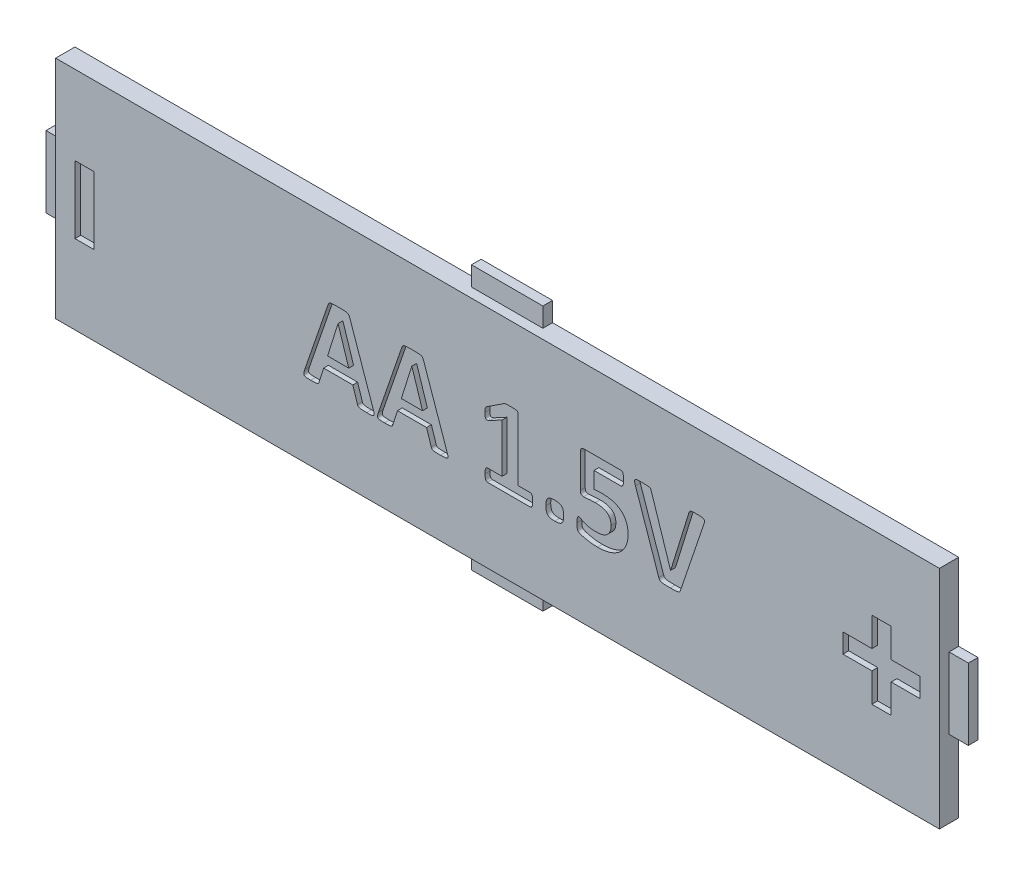
from build123d import *

# Parameters (mm, degrees)
BOSS_EXTRUDE1_DEPTH = 1
CUT_EXTRUDE1_DEPTH  = 0.25
SKETCH4_W           = 2.1
SKETCH4_H           = 2.1
CUT_EXTRUDE3_DEPTH  = 0.5
FILLET2_R           = 0.4
SKETCH6_W           = 1
SKETCH6_H           = 3.5
CUT_EXTRUDE4_DEPTH  = 0.3
SKETCH7_W           = 1
SKETCH7_H           = 3.7
SKETCH7_W_2         = 3.7
SKETCH7_H_2         = 1
CUT_EXTRUDE5_DEPTH  = 0.5


with BuildPart() as part:
    # Sketch1 → Boss-Extrude1 (new body)
    with BuildSketch(Plane.XY):
        Polygon((-22.9, -5.85), (-1.85, -5.85), (-1.85, -6.85), (1.85, -6.85), (1.85, -5.85), (22.9, -5.85), (22.9, -1.85), (23.9, -1.85), (23.9, 1.85), (22.9, 1.85), (22.9, 5.85), (1.85, 5.85), (1.85, 6.85), (-1.85, 6.85), (-1.85, 5.85), (-22.9, 5.85), (-22.9, 1.85), (-23.9, 1.85), (-23.9, -1.85), (-22.9, -1.85), align=None)
    extrude(amount=BOSS_EXTRUDE1_DEPTH)

    # Sketch2 → Cut-Extrude1 (cut)
    with BuildSketch(Plane.XY.offset(1)):
        with BuildLine():
            add(Edge.make_bspline(
                [(-6.441176471, -1.681066176), (-6.43514215, -1.698463246), (-6.423893064, -1.73089459), (-6.411134097, -1.777714399), (-6.400914328, -1.81840243), (-6.393947438, -1.853881891), (-6.391326647, -1.884608418), (-6.39520632, -1.911109035), (-6.403122486, -1.934523301), (-6.418807872, -1.953302348), (-6.439899264, -1.968606454), (-6.467908333, -1.979050301), (-6.501623162, -1.988432883), (-6.542462837, -1.993400755), (-6.590374631, -1.995378977), (-6.645792762, -1.998848309), (-6.709870331, -1.998953944), (-6.755210304, -1.999635957), (-6.779411765, -2)],
                knots=[0, 0, 0, 0, 5.5224e-05, 0.000102947, 0.000145525, 0.000181039, 0.000211426, 0.000237422, 0.000260981, 0.000284522, 0.000309525, 0.000338371, 0.000373598, 0.000414414, 0.00046137, 0.000517504, 0.00058093, 0.000653546, 0.000653546, 0.000653546, 0.000653546], degree=3))
            add(Edge.make_bspline(
                [(-6.779411765, -2), (-6.804227611, -2.000059076), (-6.851104114, -2.000170668), (-6.916990313, -1.999438733), (-6.974262144, -1.997235534), (-7.035664591, -1.995552473), (-7.097179219, -1.989698559), (-7.156329437, -1.980048369), (-7.198777842, -1.963881988), (-7.227688195, -1.940038839), (-7.24419154, -1.908504263), (-7.252150138, -1.886125934), (-7.256433824, -1.874080882)],
                knots=[0, 0, 0, 0, 7.4449e-05, 0.000140631, 0.000197646, 0.000246394, 0.000324864, 0.000382907, 0.000425752, 0.000459648, 0.000492595, 0.000531001, 0.000531001, 0.000531001, 0.000531001], degree=3))
            Line((-7.256433824, -1.874080882), (-7.500919118, -1.117647059))
            Line((-7.500919118, -1.117647059), (-9.010110294, -1.117647059))
            Line((-9.010110294, -1.117647059), (-9.241727941, -1.852941176))
            add(Edge.make_bspline(
                [(-9.241727941, -1.852941176), (-9.245919816, -1.86624811), (-9.253902368, -1.891588393), (-9.272028902, -1.926589366), (-9.301223981, -1.954190463), (-9.342387527, -1.974913155), (-9.399235471, -1.987349905), (-9.473663173, -1.996392786), (-9.570163526, -1.998447493), (-9.641859217, -1.999442899), (-9.681985294, -2)],
                knots=[0, 0, 0, 0, 4.1858e-05, 7.9709e-05, 0.00011676, 0.000160338, 0.000216291, 0.000290393, 0.000385133, 0.000505552, 0.000505552, 0.000505552, 0.000505552], degree=3))
            add(Edge.make_bspline(
                [(-9.681985294, -2), (-9.704351499, -1.999769411), (-9.746640373, -1.999333426), (-9.806400512, -1.997568311), (-9.858491194, -1.994780433), (-9.903390712, -1.991668492), (-9.941045498, -1.985572768), (-9.97271125, -1.976296067), (-9.998311499, -1.964078749), (-10.024660548, -1.942534901), (-10.042135205, -1.900772413), (-10.040106686, -1.839358846), (-10.02070276, -1.763253372), (-10.002794458, -1.706685478), (-9.992647059, -1.674632353)],
                knots=[0, 0, 0, 0, 6.7102e-05, 0.000126873, 0.000179335, 0.000223606, 0.000261835, 0.000293528, 0.000322301, 0.000346426, 0.000394123, 0.000451116, 0.000528278, 0.000629168, 0.000629168, 0.000629168, 0.000629168], degree=3))
            Line((-9.992647059, -1.674632353), (-8.783088235, 1.840992647))
            add(Edge.make_bspline(
                [(-8.783088235, 1.840992647), (-8.776768306, 1.856793782), (-8.765081152, 1.886014088), (-8.741799782, 1.925905888), (-8.706874844, 1.95706308), (-8.656070861, 1.97630304), (-8.589651982, 1.990860253), (-8.521210497, 1.995308723), (-8.45527723, 1.997267632), (-8.395539456, 1.99939096), (-8.328127436, 2.000182536), (-8.280637372, 2.000063154), (-8.255514706, 2)],
                knots=[0, 0, 0, 0, 5.105e-05, 9.4405e-05, 0.000137378, 0.000188428, 0.000255322, 0.000341116, 0.000393538, 0.000453309, 0.000520411, 0.000595778, 0.000595778, 0.000595778, 0.000595778], degree=3))
            add(Edge.make_bspline(
                [(-8.255514706, 2), (-8.226715577, 2.000060532), (-8.171872879, 2.000175804), (-8.094351935, 1.999407864), (-8.026033407, 1.997289207), (-7.951534629, 1.995274375), (-7.875169887, 1.991036748), (-7.80104759, 1.976372259), (-7.745233752, 1.95675726), (-7.706343614, 1.924201189), (-7.681056865, 1.881268088), (-7.669740277, 1.849195453), (-7.663602941, 1.831801471)],
                knots=[0, 0, 0, 0, 8.6397e-05, 0.000164527, 0.000232567, 0.000291419, 0.000388206, 0.00046139, 0.000517884, 0.000563545, 0.000610212, 0.000665512, 0.000665512, 0.000665512, 0.000665512], degree=3))
            Line((-7.663602941, 1.831801471), (-6.441176471, -1.681066176))
        make_face()
        Polygon((-8.264705882, 1.252757353), (-8.267463235, 1.252757353), (-8.806985294, -0.470588235), (-7.709558824, -0.470588235), align=None, mode=Mode.SUBTRACT)
        with BuildLine():
            add(Edge.make_bspline(
                [(-2.617647059, -1.681066176), (-2.611612738, -1.698463246), (-2.600363653, -1.73089459), (-2.587604685, -1.777714399), (-2.577384916, -1.81840243), (-2.570418026, -1.853881891), (-2.567797235, -1.884608418), (-2.571676909, -1.911109035), (-2.579593074, -1.934523301), (-2.59527846, -1.953302348), (-2.616369852, -1.968606454), (-2.644378921, -1.979050301), (-2.67809375, -1.988432883), (-2.718933426, -1.993400755), (-2.76684522, -1.995378977), (-2.82226335, -1.998848309), (-2.886340919, -1.998953944), (-2.931680892, -1.999635957), (-2.955882353, -2)],
                knots=[0, 0, 0, 0, 5.5224e-05, 0.000102947, 0.000145525, 0.000181039, 0.000211426, 0.000237422, 0.000260981, 0.000284522, 0.000309525, 0.000338371, 0.000373598, 0.000414414, 0.00046137, 0.000517504, 0.00058093, 0.000653546, 0.000653546, 0.000653546, 0.000653546], degree=3))
            add(Edge.make_bspline(
                [(-2.955882353, -2), (-2.980698199, -2.000059076), (-3.027574703, -2.000170668), (-3.093460901, -1.999438733), (-3.150732732, -1.997235534), (-3.212135179, -1.995552473), (-3.273649807, -1.989698559), (-3.332800026, -1.980048369), (-3.37524843, -1.963881988), (-3.404158783, -1.940038839), (-3.420662129, -1.908504263), (-3.428620726, -1.886125934), (-3.432904412, -1.874080882)],
                knots=[0, 0, 0, 0, 7.4449e-05, 0.000140631, 0.000197646, 0.000246394, 0.000324864, 0.000382907, 0.000425752, 0.000459648, 0.000492595, 0.000531001, 0.000531001, 0.000531001, 0.000531001], degree=3))
            Line((-3.432904412, -1.874080882), (-3.677389706, -1.117647059))
            Line((-3.677389706, -1.117647059), (-5.186580882, -1.117647059))
            Line((-5.186580882, -1.117647059), (-5.418198529, -1.852941176))
            add(Edge.make_bspline(
                [(-5.418198529, -1.852941176), (-5.422390404, -1.86624811), (-5.430372956, -1.891588393), (-5.44849949, -1.926589366), (-5.477694569, -1.954190463), (-5.518858115, -1.974913155), (-5.57570606, -1.987349905), (-5.650133761, -1.996392786), (-5.746634114, -1.998447493), (-5.818329805, -1.999442899), (-5.858455882, -2)],
                knots=[0, 0, 0, 0, 4.1858e-05, 7.9709e-05, 0.00011676, 0.000160338, 0.000216291, 0.000290393, 0.000385133, 0.000505552, 0.000505552, 0.000505552, 0.000505552], degree=3))
            add(Edge.make_bspline(
                [(-5.858455882, -2), (-5.880822087, -1.999769411), (-5.923110961, -1.999333426), (-5.9828711, -1.997568311), (-6.034961783, -1.994780433), (-6.0798613, -1.991668492), (-6.117516086, -1.985572768), (-6.149181838, -1.976296067), (-6.174782087, -1.964078749), (-6.201131136, -1.942534901), (-6.218605793, -1.900772413), (-6.216577274, -1.839358846), (-6.197173348, -1.763253372), (-6.179265047, -1.706685478), (-6.169117647, -1.674632353)],
                knots=[0, 0, 0, 0, 6.7102e-05, 0.000126873, 0.000179335, 0.000223606, 0.000261835, 0.000293528, 0.000322301, 0.000346426, 0.000394123, 0.000451116, 0.000528278, 0.000629168, 0.000629168, 0.000629168, 0.000629168], degree=3))
            Line((-6.169117647, -1.674632353), (-4.959558824, 1.840992647))
            add(Edge.make_bspline(
                [(-4.959558824, 1.840992647), (-4.953238894, 1.856793782), (-4.941551741, 1.886014088), (-4.91827037, 1.925905888), (-4.883345433, 1.95706308), (-4.83254145, 1.97630304), (-4.76612257, 1.990860253), (-4.697681085, 1.995308723), (-4.631747818, 1.997267632), (-4.572010044, 1.99939096), (-4.504598024, 2.000182536), (-4.45710796, 2.000063154), (-4.431985294, 2)],
                knots=[0, 0, 0, 0, 5.105e-05, 9.4405e-05, 0.000137378, 0.000188428, 0.000255322, 0.000341116, 0.000393538, 0.000453309, 0.000520411, 0.000595778, 0.000595778, 0.000595778, 0.000595778], degree=3))
            add(Edge.make_bspline(
                [(-4.431985294, 2), (-4.403186165, 2.000060532), (-4.348343467, 2.000175804), (-4.270822524, 1.999407864), (-4.202503995, 1.997289207), (-4.128005217, 1.995274375), (-4.051640475, 1.991036748), (-3.977518178, 1.976372259), (-3.92170434, 1.95675726), (-3.882814203, 1.924201189), (-3.857527453, 1.881268088), (-3.846210865, 1.849195453), (-3.840073529, 1.831801471)],
                knots=[0, 0, 0, 0, 8.6397e-05, 0.000164527, 0.000232567, 0.000291419, 0.000388206, 0.00046139, 0.000517884, 0.000563545, 0.000610212, 0.000665512, 0.000665512, 0.000665512, 0.000665512], degree=3))
            Line((-3.840073529, 1.831801471), (-2.617647059, -1.681066176))
        make_face()
        Polygon((-4.441176471, 1.252757353), (-4.443933824, 1.252757353), (-4.983455882, -0.470588235), (-3.886029412, -0.470588235), align=None, mode=Mode.SUBTRACT)
        with BuildLine():
            add(Edge.make_bspline(
                [(1.823529412, -1.681066176), (1.823463336, -1.708670782), (1.823341898, -1.759404012), (1.815553837, -1.828767687), (1.805678764, -1.885535073), (1.79009576, -1.929490513), (1.771757062, -1.962408316), (1.750141338, -1.984620328), (1.725346823, -1.998330266), (1.707581573, -1.999436385), (1.698529412, -2)],
                knots=[0, 0, 0, 0, 8.2741e-05, 0.000152066, 0.000209207, 0.000255144, 0.0002914, 0.000321296, 0.000347195, 0.000374102, 0.000374102, 0.000374102, 0.000374102], degree=3))
            Line((1.698529412, -2), (-0.525735294, -2))
            add(Edge.make_bspline(
                [(-0.525735294, -2), (-0.533828139, -1.999297033), (-0.550589773, -1.99784107), (-0.574550612, -1.984881933), (-0.595190944, -1.962021237), (-0.613710959, -1.929566078), (-0.629121518, -1.885502034), (-0.639390772, -1.828835037), (-0.645359368, -1.759317359), (-0.646459683, -1.7086535), (-0.647058824, -1.681066176)],
                knots=[0, 0, 0, 0, 2.4178e-05, 5.0077e-05, 7.933e-05, 0.000115586, 0.000161524, 0.000218664, 0.000287898, 0.000370664, 0.000370664, 0.000370664, 0.000370664], degree=3))
            add(Edge.make_bspline(
                [(-0.647058824, -1.681066176), (-0.646699586, -1.652881612), (-0.646042735, -1.601347219), (-0.641661078, -1.530748077), (-0.630471054, -1.473814673), (-0.616373386, -1.428606742), (-0.597911975, -1.3945121), (-0.576675694, -1.36995921), (-0.55104218, -1.355766058), (-0.532935014, -1.353881719), (-0.523897059, -1.352941176)],
                knots=[0, 0, 0, 0, 8.4579e-05, 0.000154649, 0.00021179, 0.000258294, 0.000296145, 0.000327368, 0.00035451, 0.000381557, 0.000381557, 0.000381557, 0.000381557], degree=3))
            Line((-0.523897059, -1.352941176), (0.235294118, -1.352941176))
            Line((0.235294118, -1.352941176), (0.235294118, 1.176470588))
            Line((0.235294118, 1.176470588), (-0.413602941, 0.823529412))
            add(Edge.make_bspline(
                [(-0.413602941, 0.823529412), (-0.435180914, 0.813929222), (-0.473063436, 0.797075026), (-0.525404981, 0.779751125), (-0.569906652, 0.778341719), (-0.606701336, 0.798574373), (-0.627952931, 0.840667044), (-0.640718068, 0.899595145), (-0.645197908, 0.981284747), (-0.646382661, 1.043523314), (-0.647058824, 1.079044118)],
                knots=[0, 0, 0, 0, 7.0844e-05, 0.000124374, 0.000164825, 0.000200624, 0.000243499, 0.000301235, 0.000381457, 0.00048811, 0.00048811, 0.00048811, 0.00048811], degree=3))
            add(Edge.make_bspline(
                [(-0.647058824, 1.079044118), (-0.646781225, 1.102022887), (-0.646281444, 1.143393247), (-0.645211146, 1.200180263), (-0.64033152, 1.246908359), (-0.629930775, 1.285869035), (-0.615948122, 1.31858159), (-0.594674676, 1.345227508), (-0.567314188, 1.368798158), (-0.546413484, 1.383476764), (-0.534926471, 1.391544118)],
                knots=[0, 0, 0, 0, 6.894e-05, 0.000124118, 0.000170403, 0.00020942, 0.000244791, 0.00027623, 0.00031073, 0.000352829, 0.000352829, 0.000352829, 0.000352829], degree=3))
            Line((-0.534926471, 1.391544118), (0.330882353, 1.958639706))
            add(Edge.make_bspline(
                [(0.330882353, 1.958639706), (0.33651643, 1.96297208), (0.348423394, 1.972128048), (0.372033438, 1.979454741), (0.399727977, 1.987326536), (0.435261215, 1.992312861), (0.47963741, 1.997426151), (0.536478022, 1.997983825), (0.607818924, 2.000715495), (0.660839787, 2.000255319), (0.690257353, 2)],
                knots=[0, 0, 0, 0, 2.116e-05, 4.4719e-05, 7.3256e-05, 0.000107707, 0.000152064, 0.000207241, 0.000278037, 0.000366272, 0.000366272, 0.000366272, 0.000366272], degree=3))
            add(Edge.make_bspline(
                [(0.690257353, 2), (0.726419743, 1.999966625), (0.790802162, 1.999907206), (0.876915163, 1.996350072), (0.942865406, 1.990790148), (0.991011383, 1.981507782), (1.025867207, 1.971400808), (1.046692212, 1.95277177), (1.05812401, 1.930396795), (1.058580088, 1.914054145), (1.058823529, 1.905330882)],
                knots=[0, 0, 0, 0, 0.00010846, 0.000193098, 0.000258672, 0.00030644, 0.000340756, 0.000365487, 0.000388095, 0.000413977, 0.000413977, 0.000413977, 0.000413977], degree=3))
            Line((1.058823529, 1.905330882), (1.058823529, -1.352941176))
            Line((1.058823529, -1.352941176), (1.701286765, -1.352941176))
            add(Edge.make_bspline(
                [(1.701286765, -1.352941176), (1.710325078, -1.353881658), (1.72843296, -1.355765873), (1.754060818, -1.369959998), (1.775323592, -1.394508331), (1.793652335, -1.428625792), (1.808393488, -1.473613242), (1.816142349, -1.531053339), (1.823184393, -1.601237293), (1.823407471, -1.652851985), (1.823529412, -1.681066176)],
                knots=[0, 0, 0, 0, 2.7048e-05, 5.4189e-05, 8.5412e-05, 0.000123263, 0.000169768, 0.000226582, 0.000296731, 0.000381309, 0.000381309, 0.000381309, 0.000381309], degree=3))
        make_face()
        with BuildLine():
            add(Edge.make_bspline(
                [(3.426470588, -1.522058824), (3.425334538, -1.565313272), (3.423251243, -1.644633563), (3.406376522, -1.753050052), (3.374964728, -1.839072629), (3.329068465, -1.905449491), (3.263096851, -1.950018064), (3.180369057, -1.978983157), (3.078571201, -1.99695643), (3.004374792, -1.998930109), (2.964154412, -2)],
                knots=[0, 0, 0, 0, 0.000129755, 0.000237946, 0.000327559, 0.000402567, 0.000475757, 0.000562139, 0.000663995, 0.000784571, 0.000784571, 0.000784571, 0.000784571], degree=3))
            add(Edge.make_bspline(
                [(2.964154412, -2), (2.923965572, -1.998800388), (2.850183052, -1.996598027), (2.74865283, -1.98029781), (2.667169587, -1.950469499), (2.601428274, -1.907764129), (2.55624685, -1.842974933), (2.526180231, -1.760236588), (2.508569111, -1.656968489), (2.506592775, -1.581570143), (2.505514706, -1.540441176)],
                knots=[0, 0, 0, 0, 0.000120576, 0.000221365, 0.000306888, 0.00037955, 0.000452532, 0.000539241, 0.000642002, 0.000765332, 0.000765332, 0.000765332, 0.000765332], degree=3))
            add(Edge.make_bspline(
                [(2.505514706, -1.540441176), (2.505895852, -1.517454203), (2.50662338, -1.473576869), (2.511305012, -1.410688065), (2.51830138, -1.353504139), (2.528905718, -1.301974357), (2.543958123, -1.257036021), (2.560136646, -1.217405117), (2.580512398, -1.18384149), (2.613094487, -1.14589535), (2.668942946, -1.109321961), (2.751805463, -1.078012297), (2.855152152, -1.062496621), (2.93011193, -1.060111456), (2.970588235, -1.058823529)],
                knots=[0, 0, 0, 0, 6.8958e-05, 0.000131627, 0.000189085, 0.000241724, 0.000289101, 0.000331099, 0.000369877, 0.000406365, 0.000480307, 0.000567016, 0.000670522, 0.000792016, 0.000792016, 0.000792016, 0.000792016], degree=3))
            add(Edge.make_bspline(
                [(2.970588235, -1.058823529), (3.010162929, -1.060060867), (3.083329319, -1.062348479), (3.183965108, -1.078409797), (3.265372659, -1.108400438), (3.33029664, -1.152046809), (3.37578326, -1.216699336), (3.405923214, -1.299809933), (3.423432846, -1.404004494), (3.425396507, -1.4803173), (3.426470588, -1.522058824)],
                knots=[0, 0, 0, 0, 0.000118741, 0.00021953, 0.000304193, 0.000377383, 0.000450365, 0.000537074, 0.000640739, 0.000765904, 0.000765904, 0.000765904, 0.000765904], degree=3))
        make_face()
        with BuildLine():
            add(Edge.make_bspline(
                [(6.764705882, -0.693933824), (6.763276245, -0.746394302), (6.760480127, -0.848997733), (6.73911744, -0.998792304), (6.703420883, -1.139965833), (6.653458704, -1.27208329), (6.591243282, -1.394742318), (6.515456697, -1.506995234), (6.429465703, -1.610509816), (6.330068054, -1.702660077), (6.220196673, -1.784602369), (6.099854892, -1.856783072), (5.968812539, -1.918125128), (5.82799117, -1.969563543), (5.678235116, -2.009940812), (5.519839318, -2.038017081), (5.353666986, -2.056058848), (5.239937917, -2.057890287), (5.181985294, -2.058823529)],
                knots=[0, 0, 0, 0, 0.000157341, 0.000307731, 0.000452853, 0.000593346, 0.000730639, 0.000864471, 0.000998864, 0.001133473, 0.001270054, 0.001409396, 0.00155371, 0.001703458, 0.001858637, 0.002018367, 0.002185642, 0.002359443, 0.002359443, 0.002359443, 0.002359443], degree=3))
            add(Edge.make_bspline(
                [(5.181985294, -2.058823529), (5.120984123, -2.057748267), (5.002144856, -2.055653497), (4.829900949, -2.039976823), (4.671160012, -2.01498533), (4.52898044, -1.985620594), (4.408080634, -1.951815577), (4.322288619, -1.923053408), (4.266232293, -1.901185346), (4.235138452, -1.885444989), (4.20982286, -1.872892725), (4.187540781, -1.856460964), (4.167692515, -1.834726845), (4.150299971, -1.806298785), (4.139893859, -1.773348287), (4.130037911, -1.735753853), (4.124409937, -1.690064234), (4.119433998, -1.634913473), (4.11848825, -1.569236839), (4.117940388, -1.521748872), (4.117647059, -1.496323529)],
                knots=[0, 0, 0, 0, 0.000182988, 0.000356487, 0.000518327, 0.000664882, 0.000791767, 0.000894659, 0.000936304, 0.000972067, 0.000999209, 0.001020901, 0.001054721, 0.001086877, 0.001120016, 0.001157913, 0.001203407, 0.001257829, 0.001324031, 0.001400323, 0.001400323, 0.001400323, 0.001400323], degree=3))
            add(Edge.make_bspline(
                [(4.117647059, -1.496323529), (4.11815898, -1.46875123), (4.119092323, -1.418480881), (4.121759495, -1.349308122), (4.129665503, -1.293201714), (4.141407408, -1.248575284), (4.156286357, -1.215200417), (4.174385413, -1.191913313), (4.196115696, -1.178344193), (4.211842285, -1.17709319), (4.219669118, -1.176470588)],
                knots=[0, 0, 0, 0, 8.2741e-05, 0.000150855, 0.000207528, 0.000252349, 0.000288941, 0.000316361, 0.000339848, 0.000363118, 0.000363118, 0.000363118, 0.000363118], degree=3))
            add(Edge.make_bspline(
                [(4.219669118, -1.176470588), (4.233063378, -1.178915991), (4.266810201, -1.185077181), (4.320369269, -1.217583618), (4.393363041, -1.255403321), (4.487377815, -1.298132887), (4.602998218, -1.339676482), (4.713706248, -1.371749136), (4.814553915, -1.391715085), (4.900392937, -1.404063983), (4.993797776, -1.40974194), (5.058512688, -1.411076134), (5.091911765, -1.411764706)],
                knots=[0, 0, 0, 0, 4.0577e-05, 0.000102233, 0.00018528, 0.000288122, 0.000411408, 0.000553693, 0.000633365, 0.000719674, 0.000813645, 0.000913866, 0.000913866, 0.000913866, 0.000913866], degree=3))
            add(Edge.make_bspline(
                [(5.091911765, -1.411764706), (5.148996627, -1.410158846), (5.258738251, -1.407071694), (5.391844815, -1.383484952), (5.488307064, -1.353027283), (5.554761735, -1.327558433), (5.614280615, -1.293300922), (5.668769652, -1.254883342), (5.717910596, -1.210746465), (5.760069077, -1.160468234), (5.79757794, -1.106075996), (5.827590595, -1.045503021), (5.853250394, -0.979672132), (5.869962732, -0.907245516), (5.880281671, -0.828729727), (5.881643595, -0.774545122), (5.882352941, -0.746323529)],
                knots=[0, 0, 0, 0, 0.000171203, 0.000329125, 0.000403255, 0.000474598, 0.000542089, 0.000608654, 0.000674376, 0.000739575, 0.00080509, 0.000872091, 0.000941908, 0.001016589, 0.001094454, 0.001179093, 0.001179093, 0.001179093, 0.001179093], degree=3))
            add(Edge.make_bspline(
                [(5.882352941, -0.746323529), (5.881829138, -0.721794804), (5.880811094, -0.67412169), (5.872776009, -0.60476126), (5.857714524, -0.539930063), (5.837727712, -0.478714355), (5.811169927, -0.421937022), (5.77842803, -0.369269068), (5.739060007, -0.32142244), (5.692017438, -0.279052122), (5.639522924, -0.239541086), (5.578496672, -0.207029243), (5.510628962, -0.179461997), (5.435692826, -0.156200809), (5.352791941, -0.13946406), (5.262005116, -0.126267036), (5.162789511, -0.11937546), (5.093758866, -0.118237904), (5.057904412, -0.117647059)],
                knots=[0, 0, 0, 0, 7.3581e-05, 0.000143009, 0.000209007, 0.00027295, 0.000335861, 0.000396558, 0.000458576, 0.000521022, 0.000586098, 0.000655197, 0.000727737, 0.000805651, 0.000890195, 0.000981183, 0.00108072, 0.001188292, 0.001188292, 0.001188292, 0.001188292], degree=3))
            add(Edge.make_bspline(
                [(5.057904412, -0.117647059), (5.001176679, -0.118305369), (4.892747981, -0.119563656), (4.737963684, -0.135104105), (4.595625763, -0.151899338), (4.504030935, -0.153590603), (4.459558824, -0.154411765)],
                knots=[0, 0, 0, 0, 0.000170099, 0.000325125, 0.000466424, 0.000599775, 0.000599775, 0.000599775, 0.000599775], degree=3))
            add(Edge.make_bspline(
                [(4.459558824, -0.154411765), (4.445717647, -0.153984755), (4.419891625, -0.153188004), (4.384026353, -0.144758192), (4.353988549, -0.131483976), (4.329760124, -0.110698602), (4.313450185, -0.081398625), (4.30127413, -0.04437977), (4.296030262, 0.001704223), (4.294787654, 0.03523124), (4.294117647, 0.053308824)],
                knots=[0, 0, 0, 0, 4.1452e-05, 7.7345e-05, 0.000109828, 0.000139139, 0.000171295, 0.000209079, 0.000255483, 0.000309781, 0.000309781, 0.000309781, 0.000309781], degree=3))
            Line((4.294117647, 0.053308824), (4.294117647, 1.771139706))
            add(Edge.make_bspline(
                [(4.294117647, 1.771139706), (4.294444374, 1.790187018), (4.295049825, 1.825483201), (4.304433576, 1.874105566), (4.318607092, 1.914779381), (4.340088433, 1.947545097), (4.36984738, 1.971598971), (4.405558828, 1.989089555), (4.449060775, 1.997792803), (4.479747837, 1.999225906), (4.496323529, 2)],
                knots=[0, 0, 0, 0, 5.7052e-05, 0.000105722, 0.000147891, 0.00018562, 0.000221513, 0.000261386, 0.000303755, 0.000353523, 0.000353523, 0.000353523, 0.000353523], degree=3))
            Line((4.496323529, 2), (6.401654412, 2))
            add(Edge.make_bspline(
                [(6.401654412, 2), (6.411054855, 1.999156219), (6.43042298, 1.997417741), (6.456740563, 1.980871924), (6.481042529, 1.956083932), (6.498311315, 1.918439768), (6.513406417, 1.870425831), (6.522221176, 1.809370655), (6.528962345, 1.735145541), (6.529253314, 1.681090675), (6.529411765, 1.651654412)],
                knots=[0, 0, 0, 0, 2.7954e-05, 5.7595e-05, 9.0747e-05, 0.000131031, 0.000180158, 0.000241657, 0.000315467, 0.000403722, 0.000403722, 0.000403722, 0.000403722], degree=3))
            add(Edge.make_bspline(
                [(6.529411765, 1.651654412), (6.529201964, 1.622533356), (6.528810455, 1.568190398), (6.522447566, 1.493265385), (6.512868532, 1.431023755), (6.499525637, 1.381431358), (6.482217521, 1.342814123), (6.460231587, 1.315338552), (6.433736718, 1.297400147), (6.414152731, 1.295208006), (6.404411765, 1.294117647)],
                knots=[0, 0, 0, 0, 8.7336e-05, 0.000162977, 0.000225383, 0.000276009, 0.000316711, 0.000351309, 0.000380635, 0.000409656, 0.000409656, 0.000409656, 0.000409656], degree=3))
            Line((6.404411765, 1.294117647), (5, 1.294117647))
            Line((5, 1.294117647), (5, 0.452205882))
            add(Edge.make_bspline(
                [(5, 0.452205882), (5.035512545, 0.455894874), (5.105817572, 0.46319806), (5.212565292, 0.468569795), (5.321381359, 0.469741937), (5.395220775, 0.470302271), (5.432904412, 0.470588235)],
                knots=[0, 0, 0, 0, 0.000107096, 0.00021202, 0.000320492, 0.000433547, 0.000433547, 0.000433547, 0.000433547], degree=3))
            add(Edge.make_bspline(
                [(5.432904412, 0.470588235), (5.484708247, 0.46971893), (5.585750645, 0.468023366), (5.732688717, 0.454520041), (5.870585643, 0.430406742), (5.999542288, 0.39771673), (6.119139265, 0.355397019), (6.229844089, 0.304962821), (6.330032155, 0.244398713), (6.419930324, 0.174559609), (6.500902926, 0.09752879), (6.570041393, 0.009712301), (6.63020205, -0.085818472), (6.678977411, -0.190967803), (6.71765703, -0.304303961), (6.745008159, -0.426630077), (6.761755162, -0.557438363), (6.763704679, -0.647619825), (6.764705882, -0.693933824)],
                knots=[0, 0, 0, 0, 0.000155399, 0.000303103, 0.00044212, 0.000574983, 0.000701728, 0.00082222, 0.000939338, 0.001052034, 0.001163187, 0.001273714, 0.001386436, 0.001501153, 0.001620614, 0.001745031, 0.00187659, 0.002015486, 0.002015486, 0.002015486, 0.002015486], degree=3))
        make_face()
        with BuildLine():
            add(Edge.make_bspline(
                [(9.483455882, -1.840992647), (9.478265376, -1.85687511), (9.468576219, -1.886523021), (9.444802504, -1.925885099), (9.409469242, -1.957408547), (9.357854748, -1.977438501), (9.289542924, -1.990449667), (9.220671267, -1.99530384), (9.15441632, -1.997279802), (9.095295241, -1.999377575), (9.028494865, -2.000185885), (8.981617678, -2.000064343), (8.956801471, -2)],
                knots=[0, 0, 0, 0, 5.0022e-05, 9.3377e-05, 0.00013635, 0.000189452, 0.00025705, 0.000344675, 0.000396178, 0.000455949, 0.000522132, 0.000596581, 0.000596581, 0.000596581, 0.000596581], degree=3))
            add(Edge.make_bspline(
                [(8.956801471, -2), (8.918198957, -2.00005542), (8.846813513, -2.000157906), (8.747833446, -1.999511702), (8.664444765, -1.997107062), (8.595022583, -1.992083258), (8.53834466, -1.983534406), (8.492013449, -1.974366334), (8.455172282, -1.959940345), (8.424796533, -1.943728765), (8.401076636, -1.922863469), (8.382470347, -1.897500911), (8.369491403, -1.86625446), (8.361695178, -1.843785921), (8.357536765, -1.831801471)],
                knots=[0, 0, 0, 0, 0.000115809, 0.000214159, 0.000296925, 0.000366079, 0.000422752, 0.00046891, 0.000507316, 0.000541061, 0.000571669, 0.000601267, 0.000634584, 0.000672669, 0.000672669, 0.000672669, 0.000672669], degree=3))
            Line((8.357536765, -1.831801471), (7.147058824, 1.681066176))
            add(Edge.make_bspline(
                [(7.147058824, 1.681066176), (7.141530917, 1.698521913), (7.131086803, 1.731501795), (7.116667677, 1.77777089), (7.107955459, 1.818838371), (7.100495242, 1.85381229), (7.098742699, 1.884820042), (7.104762289, 1.911323281), (7.1146732, 1.934716117), (7.132307499, 1.953659856), (7.156344498, 1.968710273), (7.187268251, 1.979016761), (7.22423424, 1.987219122), (7.268272732, 1.992395453), (7.320121419, 1.995703421), (7.381093977, 1.998775044), (7.451290349, 1.998968526), (7.501226865, 1.99964375), (7.527573529, 2)],
                knots=[0, 0, 0, 0, 5.494e-05, 0.0001038, 0.000145273, 0.000180787, 0.000211132, 0.000237451, 0.000261717, 0.000286448, 0.000313728, 0.000346002, 0.000383686, 0.000427235, 0.000478837, 0.000539562, 0.00061034, 0.000689389, 0.000689389, 0.000689389, 0.000689389], degree=3))
            add(Edge.make_bspline(
                [(7.527573529, 2), (7.550248607, 2.000202481), (7.592850409, 2.000582901), (7.652876494, 1.998095569), (7.705003149, 1.996760205), (7.761436347, 1.99312423), (7.818420507, 1.987639164), (7.873417214, 1.975236153), (7.914596214, 1.957083441), (7.939272817, 1.92622329), (7.956627326, 1.890682635), (7.965686465, 1.864403233), (7.970588235, 1.850183824)],
                knots=[0, 0, 0, 0, 6.8015e-05, 0.000127786, 0.000180208, 0.000224411, 0.000297491, 0.000351438, 0.000393777, 0.000428969, 0.000467198, 0.000512272, 0.000512272, 0.000512272, 0.000512272], degree=3))
            Line((7.970588235, 1.850183824), (8.967830882, -1.206801471))
            Line((8.967830882, -1.206801471), (8.970588235, -1.206801471))
            Line((8.970588235, -1.206801471), (9.911764706, 1.834558824))
            add(Edge.make_bspline(
                [(9.911764706, 1.834558824), (9.916384677, 1.850544817), (9.924729387, 1.87941913), (9.940554496, 1.919805753), (9.968963597, 1.950752809), (10.010898337, 1.973363684), (10.068666155, 1.9880694), (10.128569857, 1.9931333), (10.187158694, 1.996735395), (10.241729993, 1.998111172), (10.303903398, 2.000568224), (10.348036051, 2.000196269), (10.371323529, 2)],
                knots=[0, 0, 0, 0, 5.0005e-05, 9.0321e-05, 0.000128716, 0.000173177, 0.000231379, 0.000306286, 0.000353242, 0.000407501, 0.000470028, 0.000539881, 0.000539881, 0.000539881, 0.000539881], degree=3))
            add(Edge.make_bspline(
                [(10.371323529, 2), (10.393990399, 1.99959693), (10.436874141, 1.998834356), (10.497024011, 1.999220697), (10.549016188, 1.994407079), (10.593649588, 1.991749589), (10.631309852, 1.985540014), (10.662683256, 1.976426609), (10.6881275, 1.964186122), (10.712209608, 1.941262975), (10.730261654, 1.900551807), (10.72480326, 1.839589757), (10.706854789, 1.763653279), (10.687512105, 1.707567371), (10.676470588, 1.675551471)],
                knots=[0, 0, 0, 0, 6.8021e-05, 0.00012869, 0.000180291, 0.000224562, 0.000262791, 0.000294484, 0.000322438, 0.000346493, 0.00039297, 0.000449963, 0.000526228, 0.000627668, 0.000627668, 0.000627668, 0.000627668], degree=3))
            Line((10.676470588, 1.675551471), (9.483455882, -1.840992647))
        make_face()
    extrude(amount=-CUT_EXTRUDE1_DEPTH, mode=Mode.SUBTRACT)

    # Sketch4 → Cut-Extrude3 (cut)
    with BuildSketch(Plane(origin=(0, 0, 0), x_dir=(-1, 0, 0), z_dir=(0, 0, -1))):
        with Locations((-13.9, 0)):
            Rectangle(SKETCH4_W, SKETCH4_H)
    extrude(amount=-CUT_EXTRUDE3_DEPTH, mode=Mode.SUBTRACT)

    # Fillet2
    fillet2_edges = [part.edges().sort_by_distance(p)[0] for p in [
        (12.85, 1.05, 0.25),
        (12.85, -1.05, 0.25),
        (14.95, -1.05, 0.25),
        (14.95, 1.05, 0.25),
    ]]
    fillet(fillet2_edges, radius=FILLET2_R)

    # Sketch6 → Cut-Extrude4 (cut)
    with BuildSketch(Plane.XY.offset(1)):
        Polygon((20.4, 0.5), (21.9, 0.5), (21.9, -0.5), (20.4, -0.5), (20.4, -2), (19.4, -2), (19.4, -0.5), (17.9, -0.5), (17.9, 0.5), (19.4, 0.5), (19.4, 2), (20.4, 2), align=None)
        with Locations((-21.4, 0)):
            Rectangle(SKETCH6_W, SKETCH6_H)
    extrude(amount=-CUT_EXTRUDE4_DEPTH, mode=Mode.SUBTRACT)

    # Sketch7 → Cut-Extrude5 (cut)
    with BuildSketch(Plane.XY.offset(1)):
        with Locations((23.4, 0)):
            Rectangle(SKETCH7_W, SKETCH7_H)
        with Locations((-23.4, 0)):
            Rectangle(SKETCH7_W, SKETCH7_H)
        with Locations((0, 6.35)):
            Rectangle(SKETCH7_W_2, SKETCH7_H_2)
        with Locations((0, -6.35)):
            Rectangle(SKETCH7_W_2, SKETCH7_H_2)
    extrude(amount=-CUT_EXTRUDE5_DEPTH, mode=Mode.SUBTRACT)


solid = part.part
